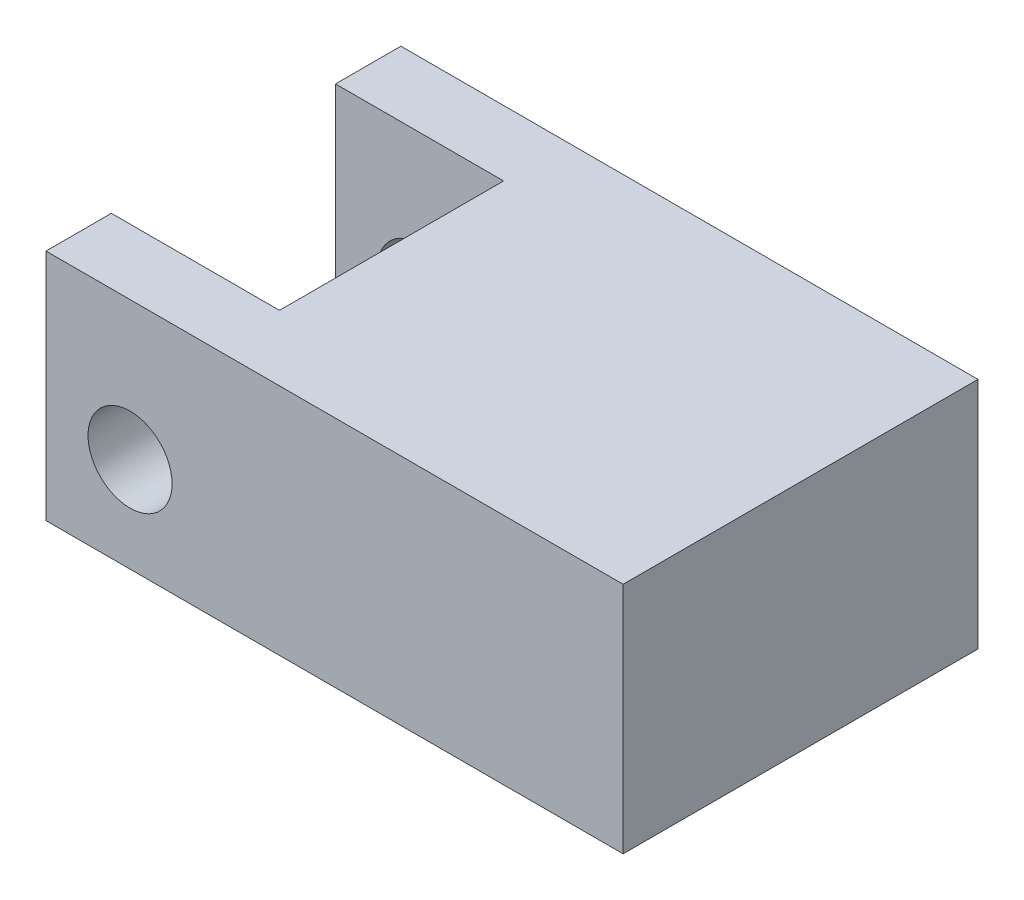
from build123d import *

# Parameters (mm, degrees)
SKETCH1_W           = 30.9
SKETCH1_H           = 12.5
BOSS_EXTRUDE1_DEPTH = 9.499999986
SKETCH2_W           = 9
SKETCH2_H           = 12
CUT_EXTRUDE1_DEPTH  = 12.5
SKETCH3_R           = 2.25
CUT_EXTRUDE2_DEPTH  = 19


with BuildPart() as part:
    # Sketch1 → Boss-Extrude1 (new body, symmetric)
    with BuildSketch(Plane.XY):
        Rectangle(SKETCH1_W, SKETCH1_H)
    extrude(amount=BOSS_EXTRUDE1_DEPTH, both=True)

    # Sketch2 → Cut-Extrude1 (cut)
    with BuildSketch(Plane(origin=(0, 6.25, 0), x_dir=(1, 0, 0), z_dir=(0, 1, 0))):
        with Locations((-10.95, 0)):
            Rectangle(SKETCH2_W, SKETCH2_H)
    extrude(amount=-CUT_EXTRUDE1_DEPTH, mode=Mode.SUBTRACT)

    # Sketch3 → Cut-Extrude2 (cut)
    with BuildSketch(Plane.XY.offset(9.499999986)):
        with Locations((-10.95, -1.17)):
            Circle(SKETCH3_R)
    extrude(amount=-CUT_EXTRUDE2_DEPTH, mode=Mode.SUBTRACT)


solid = part.part
